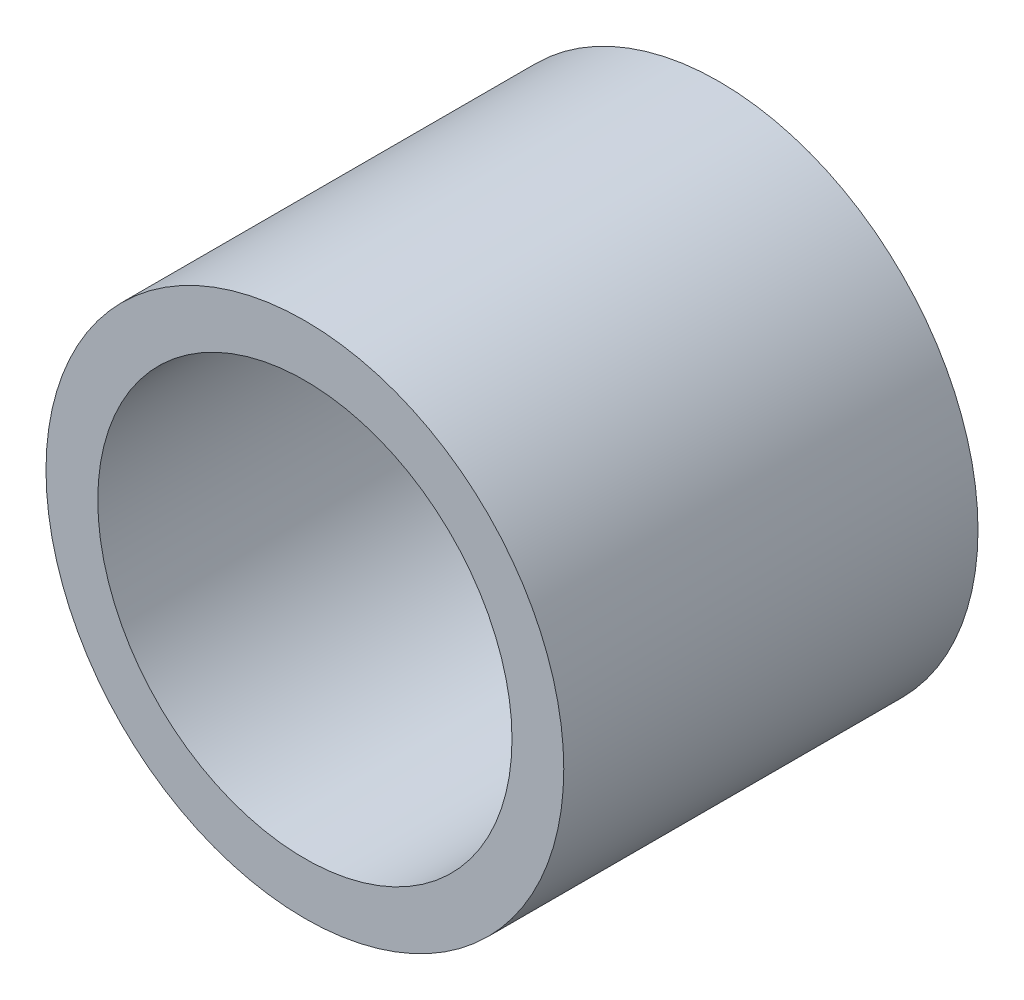
from build123d import *

# Parameters (mm, degrees)
SKETCH1_R           = 1.25
SKETCH1_R_2         = 1
BOSS_EXTRUDE1_DEPTH = 2


with BuildPart() as part:
    # Sketch1 → Boss-Extrude1 (new body)
    with BuildSketch(Plane.XY):
        Circle(SKETCH1_R)
        Circle(SKETCH1_R_2, mode=Mode.SUBTRACT)
    extrude(amount=BOSS_EXTRUDE1_DEPTH)


solid = part.part
